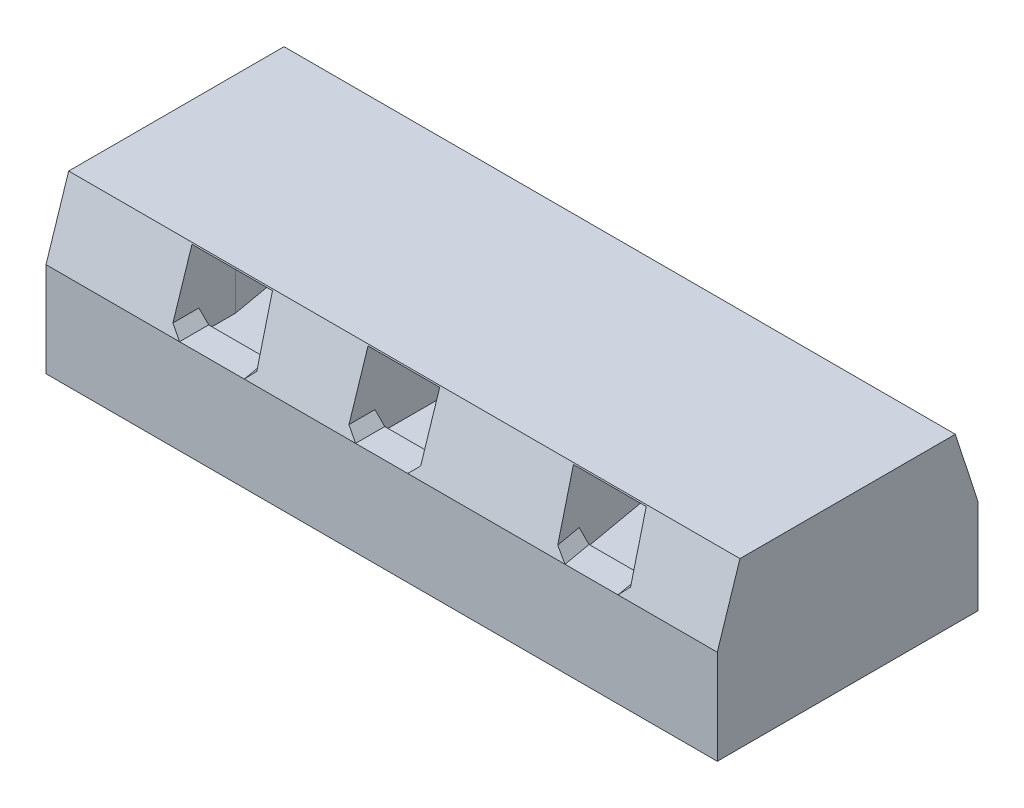
from build123d import *

# Parameters (mm, degrees)
SKETCH_1_W               = 2060
SKETCH_1_H               = 800
EXTRUDE_1_DEPTH          = 500
SKETCH_3_W               = 220
SKETCH_3_H               = 220
CUT_EXTRUDE_1_DEPTH      = 310.5
EXTRUDE_2_REACH          = 2159.22
SKETCH_5_W               = 220
SKETCH_5_H               = 210
CUT_EXTRUDE_2_DEPTH      = 1399.18310675
SKETCH_7_W               = 220
SKETCH_7_H               = 210
CUT_EXTRUDE_3_DEPTH      = 1330.488578602
CUT_EXTRUDE_3_DEPTH_BACK = 1330.488578602
CUT_EXTRUDE_4_DEPTH      = 40
SKETCH_14_W              = 220
SKETCH_14_H              = 210
CUT_EXTRUDE_5_DEPTH      = 1330.488578602
CUT_EXTRUDE_5_DEPTH_BACK = 1330.488578602
CUT_EXTRUDE_6_DEPTH      = 40
SKETCH_16_W              = 35.606145385
SKETCH_16_H              = 210
CUT_EXTRUDE_7_DEPTH      = 1399.18310675
CUT_EXTRUDE_7_DEPTH_BACK = 1399.18310675
SKETCH_18_W              = 35.606145385
SKETCH_18_H              = 210
CUT_EXTRUDE_11_DEPTH     = 1399.18310675
CUT_EXTRUDE_12_DEPTH     = 40
CUT_EXTRUDE_15_DEPTH     = 2159.151060515
CHAMFER_1_SIZE           = 30
CUT_EXTRUDE_16_DEPTH     = 40
CHAMFER_2_SIZE           = 30


with BuildPart() as part:
    # 草图1 → 凸台-拉伸1 (new body)
    with BuildSketch(Plane(origin=(0, 0, 0), x_dir=(1, 0, 0), z_dir=(0, 1, 0))):
        Rectangle(SKETCH_1_W, SKETCH_1_H)
    extrude(amount=EXTRUDE_1_DEPTH)

    # 草图3 → 切除-拉伸1 (cut, symmetric)
    with BuildSketch(Plane.XY):
        with Locations((0, 360)):
            Rectangle(SKETCH_3_W, SKETCH_3_H)
    extrude(amount=CUT_EXTRUDE_1_DEPTH, both=True, mode=Mode.SUBTRACT)

    # 凸台-拉伸2: up to this face of the body (flat: up to its plane)
    extrude_2_end = Plane(part.part.faces().sort_by_distance((-1030, 250, 0))[0])
    # 草图22 → 凸台-拉伸2 (add, up to the picked face)
    with BuildSketch(Plane(origin=(1030, 0, 0), x_dir=(0, 0, -1), z_dir=(1, 0, 0)), mode=Mode.PRIVATE) as extrude_2_sk1:
        Polygon((-330.467185006, 504), (-400, 290), (400, 290), (330.467185006, 504), align=None)
    extrude_2_tool1 = split(extrude(extrude_2_sk1.sketch, amount=-EXTRUDE_2_REACH, mode=Mode.PRIVATE), bisect_by=extrude_2_end, keep=Keep.BOTH, mode=Mode.PRIVATE)
    add(extrude_2_tool1.solids().sort_by(Axis((1030, 393.604907, 0), (-1, 0, 0)))[0])

    # 草图5 → 切除-拉伸2 (cut, through all)
    with BuildSketch(Plane.XY.offset(400)):
        with Locations((0, 395)):
            Rectangle(SKETCH_5_W, SKETCH_5_H)
    extrude(amount=-CUT_EXTRUDE_2_DEPTH, mode=Mode.SUBTRACT)

    # 草图7 → 切除-拉伸3 (cut, two sides)
    with BuildSketch(Plane(origin=(37.34572837, 0, 211.798150344), x_dir=(0.9848077530122092, 0, -0.1736481776669237), z_dir=(0.1736481776669237, 0, 0.9848077530122092))) as cut_extrude_3_sk:
        with Locations((-564.756921873, 395)):
            Rectangle(SKETCH_7_W, SKETCH_7_H)
    extrude(amount=CUT_EXTRUDE_3_DEPTH, mode=Mode.SUBTRACT)
    extrude(cut_extrude_3_sk.sketch, amount=-CUT_EXTRUDE_3_DEPTH_BACK, mode=Mode.SUBTRACT)

    # 草图10 → 切除-拉伸4 (cut)
    with BuildSketch(Plane(origin=(0, 290, 0), x_dir=(1, 0, 0), z_dir=(0, 1, 0))):
        Polygon((-614.635342741, -310.5), (-407.022752899, -310.5), (-516.521807919, 310.5), (-739.915662534, 310.5), (-630.416607514, -310.5), align=None)
    extrude(amount=-CUT_EXTRUDE_4_DEPTH, mode=Mode.SUBTRACT)

    # 草图14 → 切除-拉伸5 (cut, two sides)
    with BuildSketch(Plane(origin=(37.34572837, 0, 211.798150344), x_dir=(0.9848077530122092, 0, -0.1736481776669237), z_dir=(0.1736481776669237, 0, 0.9848077530122092))) as cut_extrude_5_sk:
        with Locations((564.756921873, 395)):
            Rectangle(SKETCH_14_W, SKETCH_14_H)
    extrude(amount=CUT_EXTRUDE_5_DEPTH, mode=Mode.SUBTRACT)
    extrude(cut_extrude_5_sk.sketch, amount=-CUT_EXTRUDE_5_DEPTH_BACK, mode=Mode.SUBTRACT)

    # 草图15 → 切除-拉伸6 (cut)
    with BuildSketch(Plane(origin=(0, 290, 0), x_dir=(1, 0, 0), z_dir=(0, 1, 0))):
        Polygon((630.416607514, 310.5), (407.022752899, 310.5), (516.521807919, -310.5), (739.915662534, -310.5), align=None)
    extrude(amount=-CUT_EXTRUDE_6_DEPTH, mode=Mode.SUBTRACT)

    # 草图16 → 切除-拉伸7 (cut, two sides)
    with BuildSketch(Plane(origin=(0, 0, -400), x_dir=(-1, 0, 0), z_dir=(0, 0, -1))) as cut_extrude_7_sk:
        with Locations((-632.438415434, 395)):
            Rectangle(SKETCH_16_W, SKETCH_16_H)
    extrude(amount=CUT_EXTRUDE_7_DEPTH, mode=Mode.SUBTRACT)
    extrude(cut_extrude_7_sk.sketch, amount=-CUT_EXTRUDE_7_DEPTH_BACK, mode=Mode.SUBTRACT)

    # 草图18 → 切除-拉伸11 (cut, through all)
    with BuildSketch(Plane.XY.offset(400)):
        with Locations((-632.438415434, 395)):
            Rectangle(SKETCH_18_W, SKETCH_18_H)
    extrude(amount=-CUT_EXTRUDE_11_DEPTH, mode=Mode.SUBTRACT)

    # 草图19 → 切除-拉伸12 (cut)
    with BuildSketch(Plane(origin=(0, 290, 0), x_dir=(1, 0, 0), z_dir=(0, 1, 0))):
        Polygon((-650.241488126, -310.5), (-630.416607514, -310.5), (-650.241488126, -198.067515011), align=None)
    extrude(amount=-CUT_EXTRUDE_12_DEPTH, mode=Mode.SUBTRACT)

    # 草图23 → 切除-拉伸15 (cut, through all)
    with BuildSketch(Plane(origin=(1030, 0, 0), x_dir=(0, 0, -1), z_dir=(1, 0, 0))):
        Polygon((400, 500), (400, 290), (331.766863791, 500), align=None)
        Polygon((-400, 500), (-400, 290), (-331.766863791, 500), align=None)
    extrude(amount=-CUT_EXTRUDE_15_DEPTH, mode=Mode.SUBTRACT)

    # 倒角1
    chamfer_1_edges = [part.edges().sort_by_distance(p)[0] for p in [
        (-399.132120513, 290, 355.25),
        (524.412440306, 290, 355.25),
        (747.806294921, 290, 355.25),
        (-650.241488126, 290, 355.25),
        (110, 290, 355.25),
        (-110, 290, 355.25),
    ]]
    chamfer(chamfer_1_edges, length=CHAMFER_1_SIZE)

    # 草图24 → 切除-拉伸16 (cut)
    with BuildSketch(Plane(origin=(0, 290, 0), x_dir=(1, 0, 0), z_dir=(0, 1, 0))):
        Polygon((650.241488126, 310.5), (630.416607514, 310.5), (650.241488126, 198.067515011), align=None)
    extrude(amount=-CUT_EXTRUDE_16_DEPTH, mode=Mode.SUBTRACT)

    # 倒角2
    chamfer_2_edges = [part.edges().sort_by_distance(p)[0] for p in [
        (399.132120513, 290, -355.25),
        (650.241488126, 290, -355.25),
        (110, 290, -355.25),
        (-110, 290, -355.25),
        (-524.412440306, 290, -355.25),
        (-747.806294921, 290, -355.25),
    ]]
    chamfer(chamfer_2_edges, length=CHAMFER_2_SIZE)


solid = part.part
